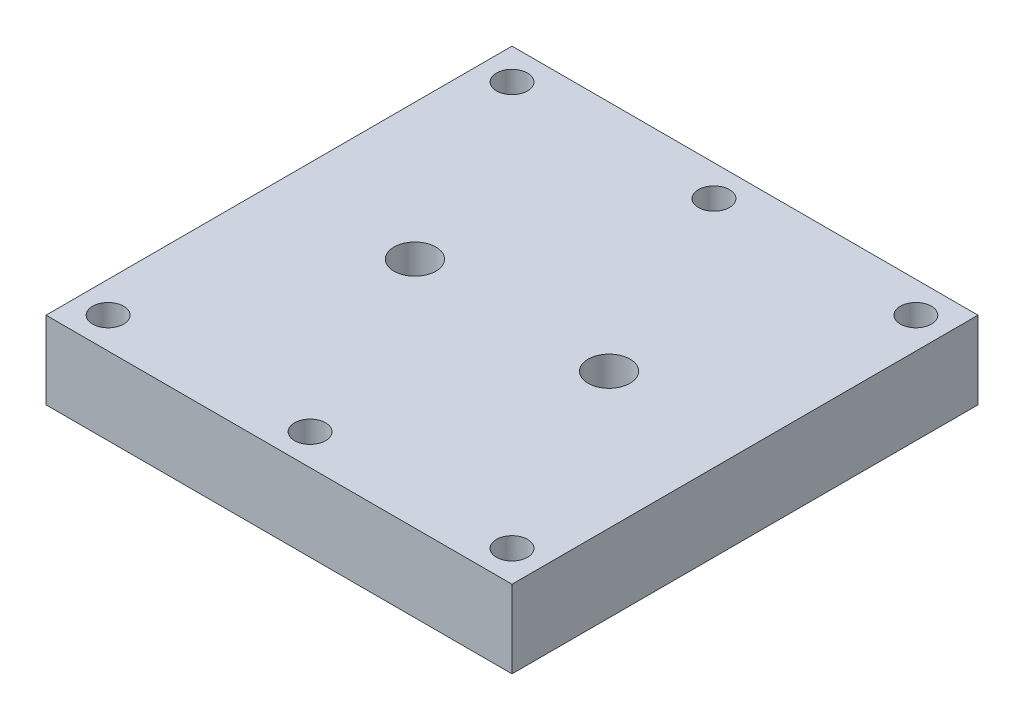
from build123d import *

# Parameters (mm, degrees)
SKETCH2_W           = 60
SKETCH2_H           = 60
BOSS_EXTRUDE1_DEPTH = 10
SKETCH3_R           = 2
CUT_EXTRUDE1_DEPTH  = 10
SKETCH4_R           = 6.35
CUT_EXTRUDE2_DEPTH  = 3.2
SKETCH5_R           = 2.7
CUT_EXTRUDE3_DEPTH  = 7
SKETCH6_R           = 0.5
CUT_EXTRUDE4_DEPTH  = 3


with BuildPart() as part:
    # Sketch2 → Boss-Extrude1 (new body)
    with BuildSketch(Plane(origin=(0, 0, 0), x_dir=(1, 0, 0), z_dir=(0, 1, 0))):
        Rectangle(SKETCH2_W, SKETCH2_H)
    extrude(amount=BOSS_EXTRUDE1_DEPTH)

    # Sketch3 → Cut-Extrude1 (cut)
    with BuildSketch(Plane(origin=(0, 10, 0), x_dir=(1, 0, 0), z_dir=(0, 1, 0))):
        with Locations((-26, 26)):
            Circle(SKETCH3_R)
        with Locations((-26, -26)):
            Circle(SKETCH3_R)
        with Locations((0, -26)):
            Circle(SKETCH3_R)
        with Locations((26, -26)):
            Circle(SKETCH3_R)
        with Locations((26, 26)):
            Circle(SKETCH3_R)
        with Locations((0, 26)):
            Circle(SKETCH3_R)
    extrude(amount=-CUT_EXTRUDE1_DEPTH, mode=Mode.SUBTRACT)

    # Sketch4 → Cut-Extrude2 (cut)
    with BuildSketch(Plane.XZ):
        Circle(SKETCH4_R)
    extrude(amount=-CUT_EXTRUDE2_DEPTH, mode=Mode.SUBTRACT)

    # Sketch5 → Cut-Extrude3 (cut)
    with BuildSketch(Plane(origin=(0, 10, 0), x_dir=(1, 0, 0), z_dir=(0, 1, 0))):
        with Locations((12.5, 0)):
            Circle(SKETCH5_R)
        with Locations((-12.5, 0)):
            Circle(SKETCH5_R)
    extrude(amount=-CUT_EXTRUDE3_DEPTH, mode=Mode.SUBTRACT)

    # Sketch6 → Cut-Extrude4 (cut)
    with BuildSketch(Plane.XZ):
        with Locations((12.5, 0)):
            Circle(SKETCH6_R)
        with Locations((-12.5, 0)):
            Circle(SKETCH6_R)
    extrude(amount=-CUT_EXTRUDE4_DEPTH, mode=Mode.SUBTRACT)


solid = part.part
